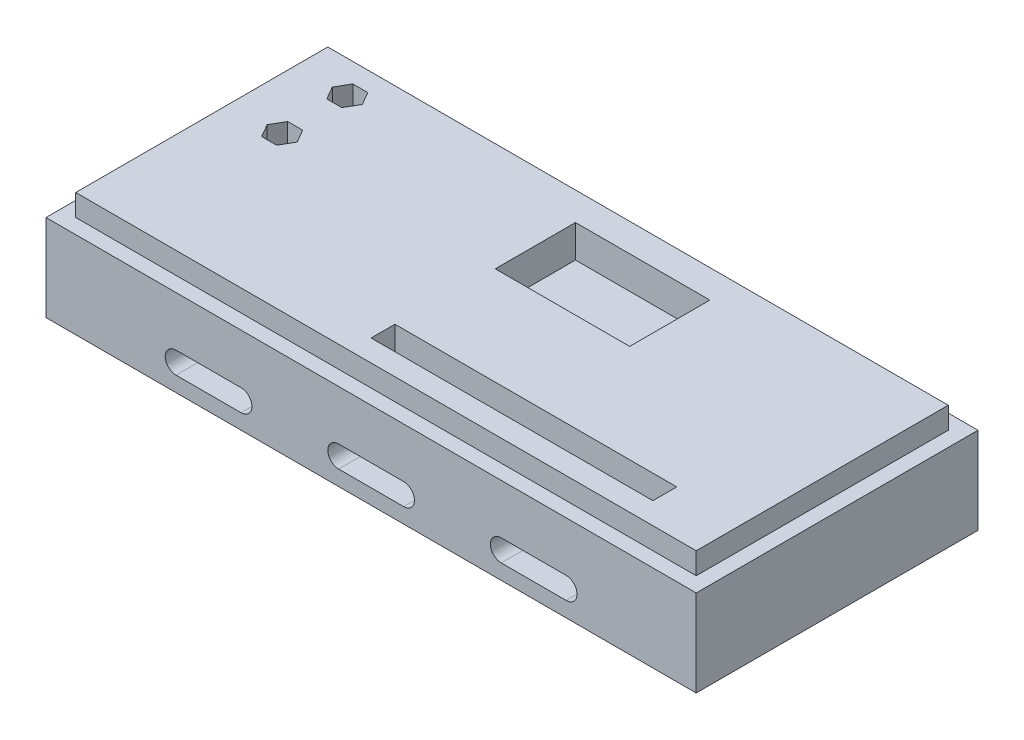
from build123d import *

# Parameters (mm, degrees)
SKETCH1_W           = 150
SKETCH1_H           = 65
BOSS_EXTRUDE1_DEPTH = 20
CUT_EXTRUDE1_DEPTH  = 66
SKETCH3_W           = 143.142
SKETCH3_H           = 58.142
BOSS_EXTRUDE2_DEPTH = 5
CUT_EXTRUDE2_DEPTH  = 6.5
SKETCH6_W           = 65
SKETCH6_H           = 5.5
CUT_EXTRUDE3_DEPTH  = 10
SKETCH7_W           = 31
SKETCH7_H           = 18.5
CUT_EXTRUDE4_DEPTH  = 7.5


with BuildPart() as part:
    # Sketch1 → Boss-Extrude1 (new body)
    with BuildSketch(Plane(origin=(0, 0, 0), x_dir=(1, 0, 0), z_dir=(0, 1, 0))):
        Rectangle(SKETCH1_W, SKETCH1_H)
    extrude(amount=BOSS_EXTRUDE1_DEPTH)

    # Sketch2 → Cut-Extrude1 (cut, through all)
    with BuildSketch(Plane.XY.offset(32.5)):
        with BuildLine():
            Line((-7.5, 8.5), (7.5, 8.5))
            ThreePointArc((7.5, 8.5), (10, 6), (7.5, 3.5))
            Line((7.5, 3.5), (-7.5, 3.5))
            ThreePointArc((-7.5, 3.5), (-10, 6), (-7.5, 8.5))
        make_face()
        with BuildLine():
            Line((-45, 8.5), (-30, 8.5))
            ThreePointArc((-30, 8.5), (-27.5, 6), (-30, 3.5))
            Line((-30, 3.5), (-45, 3.5))
            ThreePointArc((-45, 3.5), (-47.5, 6), (-45, 8.5))
        make_face()
        with BuildLine():
            Line((30, 8.5), (45, 8.5))
            ThreePointArc((45, 8.5), (47.5, 6), (45, 3.5))
            Line((45, 3.5), (30, 3.5))
            ThreePointArc((30, 3.5), (27.5, 6), (30, 8.5))
        make_face()
    extrude(amount=-CUT_EXTRUDE1_DEPTH, mode=Mode.SUBTRACT)

    # Sketch3 → Boss-Extrude2 (add)
    with BuildSketch(Plane(origin=(0, 20, 0), x_dir=(1, 0, 0), z_dir=(0, 1, 0))):
        Rectangle(SKETCH3_W, SKETCH3_H)
    extrude(amount=BOSS_EXTRUDE2_DEPTH)

    # Sketch4 → Cut-Extrude2 (cut)
    with BuildSketch(Plane(origin=(0, 25, 0), x_dir=(1, 0, 0), z_dir=(0, 1, 0))):
        Polygon((-61.303050808, 24.571), (-63.035101615, 21.571), (-61.303050808, 18.571), (-57.838949192, 18.571), (-56.106898385, 21.571), (-57.838949192, 24.571), align=None)
        Polygon((-61.303050808, 9.551), (-63.035101615, 6.551), (-61.303050808, 3.551), (-57.838949192, 3.551), (-56.106898385, 6.551), (-57.838949192, 9.551), align=None)
    extrude(amount=-CUT_EXTRUDE2_DEPTH, mode=Mode.SUBTRACT)

    # Sketch6 → Cut-Extrude3 (cut)
    with BuildSketch(Plane(origin=(0, 25, 0), x_dir=(1, 0, 0), z_dir=(0, 1, 0))):
        with Locations((24.071, -21.321)):
            Rectangle(SKETCH6_W, SKETCH6_H)
    extrude(amount=-CUT_EXTRUDE3_DEPTH, mode=Mode.SUBTRACT)

    # Sketch7 → Cut-Extrude4 (cut)
    with BuildSketch(Plane(origin=(0, 25, 0), x_dir=(1, 0, 0), z_dir=(0, 1, 0))):
        with Locations((7.571, 13.321)):
            Rectangle(SKETCH7_W, SKETCH7_H)
    extrude(amount=-CUT_EXTRUDE4_DEPTH, mode=Mode.SUBTRACT)


solid = part.part
